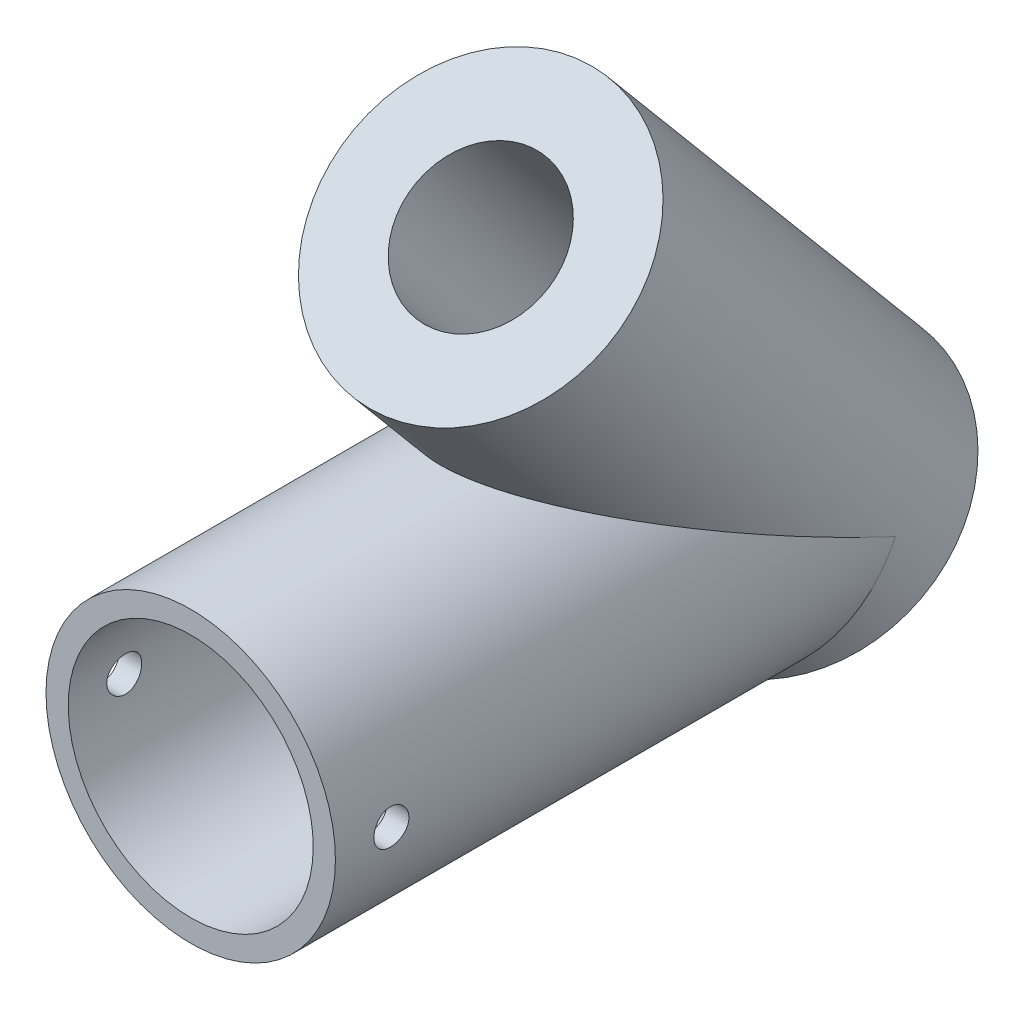
from build123d import *
from build123d.topology import SkipClean

# Parameters (mm, degrees)
SKETCH1_R                = 20.675
SKETCH1_R_2              = 17.5
BOSS_EXTRUDE1_DEPTH      = 60
SKETCH3_R                = 20.675
SKETCH3_R_2              = 10.5
BOSS_EXTRUDE2_DEPTH      = 70
BOSS_EXTRUDE5_REACH      = 88.823
BOSS_EXTRUDE5_END_RADIUS = 20.675
SKETCH1_4_R              = 20.675
SKETCH1_4_R_2            = 17.5
CUT_EXTRUDE1_DEPTH       = 95.605371432
CUT_EXTRUDE1_DEPTH_BACK  = 95.605371432
SKETCH6_R                = 10.5
CUT_EXTRUDE2_DEPTH       = 87.82333063
CUT_EXTRUDE2_DEPTH_BACK  = 87.82333063
SKETCH7_R                = 2.5


with BuildPart() as part:
    # Sketch1 → Boss-Extrude1 (new body)
    with BuildSketch(Plane.XY):
        Circle(SKETCH1_R)
        Circle(SKETCH1_R_2, mode=Mode.SUBTRACT)
    extrude(amount=BOSS_EXTRUDE1_DEPTH)

    # Sketch3 → Boss-Extrude2 (add)
    with BuildSketch(Plane(origin=(0, 45.962666587, 18.567256581), x_dir=(1, 0, 0), z_dir=(0, 0.7660444431189745, 0.6427876096865437))):
        Circle(SKETCH3_R)
        Circle(SKETCH3_R_2, mode=Mode.SUBTRACT)
    extrude(amount=-BOSS_EXTRUDE2_DEPTH)

    # Boss-Extrude5: up to this cylinder (the profile starts outside it)
    with SkipClean():  # the faces are left unmerged after this step: merging them gives an invalid solid
        boss_extrude5_end = Plane(origin=(0, 9.84807753, -11.736481777), z_dir=(0, 0.7660444431189745, 0.6427876096865437)) * Cylinder(BOSS_EXTRUDE5_END_RADIUS, 219.996, mode=Mode.PRIVATE)
        # Sketch1_4 → Boss-Extrude5 (add, up to the surface)
        with BuildSketch(Plane.XY, mode=Mode.PRIVATE) as boss_extrude5_sk1:
            Circle(SKETCH1_4_R)
            Circle(SKETCH1_4_R_2, mode=Mode.SUBTRACT)
        boss_extrude5_tool1 = extrude(boss_extrude5_sk1.sketch, amount=-BOSS_EXTRUDE5_REACH, mode=Mode.PRIVATE) - boss_extrude5_end
        add(boss_extrude5_tool1.solids().sort_by_distance((-20.090223, 0, 0))[0])

    # Sketch6 → Cut-Extrude1 (cut, two sides: drawn at the far end of the back side and taken through both)
    with SkipClean():  # the faces are left unmerged after this step: merging them gives an invalid solid
        with BuildSketch(Plane(origin=(0, 36.114589057, 30.303738358), x_dir=(1, 0, 0), z_dir=(0, 0.7660444431189743, 0.6427876096865437)).offset(-CUT_EXTRUDE1_DEPTH_BACK)):
            with Locations((0, 15.320888862)):
                Circle(SKETCH6_R)
        extrude(amount=CUT_EXTRUDE1_DEPTH + CUT_EXTRUDE1_DEPTH_BACK, mode=Mode.SUBTRACT)

    # Sketch7 → Cut-Extrude2 (cut, two sides: drawn at the far end of the back side and taken through both)
    with SkipClean():  # the faces are left unmerged after this step: merging them gives an invalid solid
        with BuildSketch(Plane(origin=(0, 0, 0), x_dir=(0, 0, -1), z_dir=(1, 0, 0)).offset(-CUT_EXTRUDE2_DEPTH_BACK)):
            with Locations((-52, 0)):
                Circle(SKETCH7_R)
        extrude(amount=CUT_EXTRUDE2_DEPTH + CUT_EXTRUDE2_DEPTH_BACK, mode=Mode.SUBTRACT)


solid = part.part
